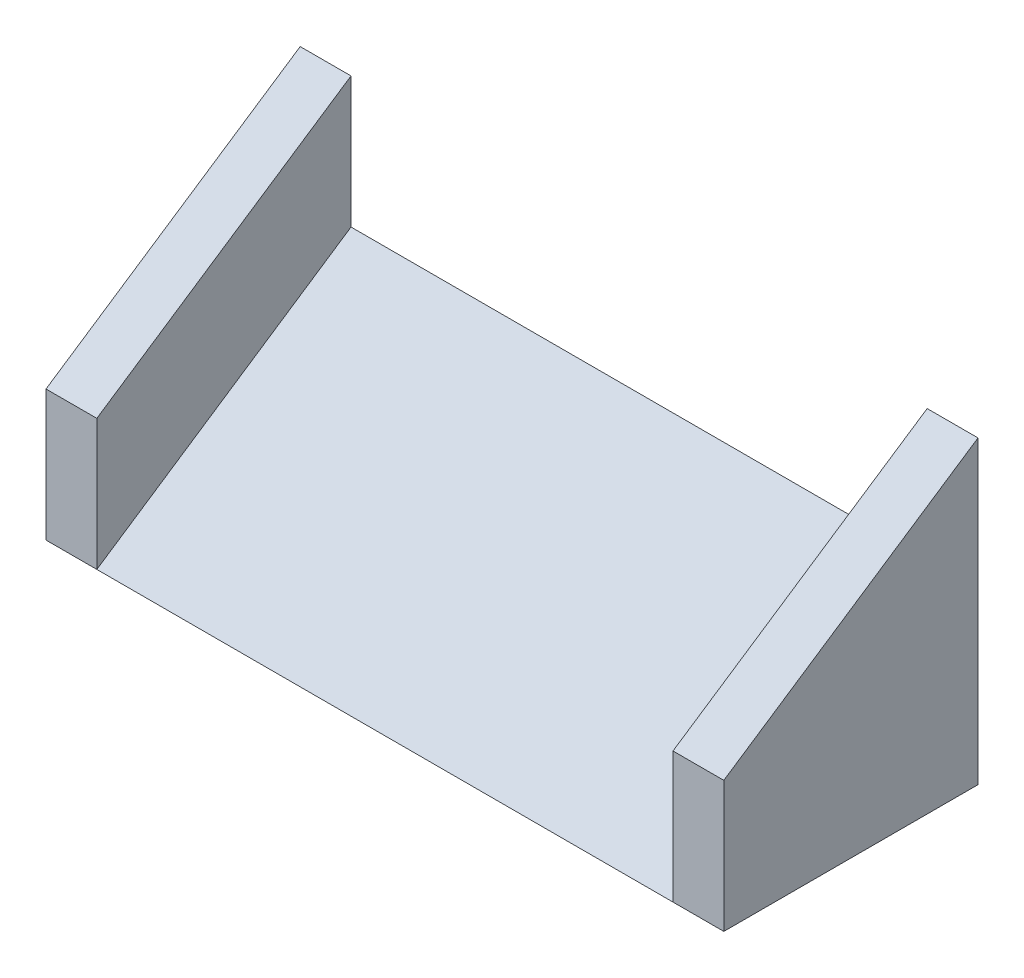
from build123d import *

# Parameters (mm, degrees)
BOSS_EXTRUDE1_DEPTH = 17
BOSS_EXTRUDE2_DEPTH = 3


with BuildPart() as part:
    # Sketch1 → Boss-Extrude1 (new body, symmetric)
    with BuildSketch(Plane(origin=(0, 0, 0), x_dir=(0, 0, -1), z_dir=(1, 0, 0))):
        Polygon((-7.5, -5), (7.5, -5), (7.5, 5), align=None)
    extrude(amount=BOSS_EXTRUDE1_DEPTH, both=True)

    # Sketch2 → Boss-Extrude2 (add)
    with BuildSketch(Plane(origin=(17, 0, 0), x_dir=(0, 0, -1), z_dir=(1, 0, 0))):
        Polygon((-7.5, -5), (-7.5, 2.722617257), (7.5, 12.722617257), (7.5, -5), align=None)
    boss_extrude2 = extrude(amount=BOSS_EXTRUDE2_DEPTH)

    # Mirror1: Boss-Extrude2 across plane
    add(boss_extrude2.mirror(Plane(origin=(0, 0, 0), x_dir=(0, 0, 1), z_dir=(1, 0, 0))))


solid = part.part
